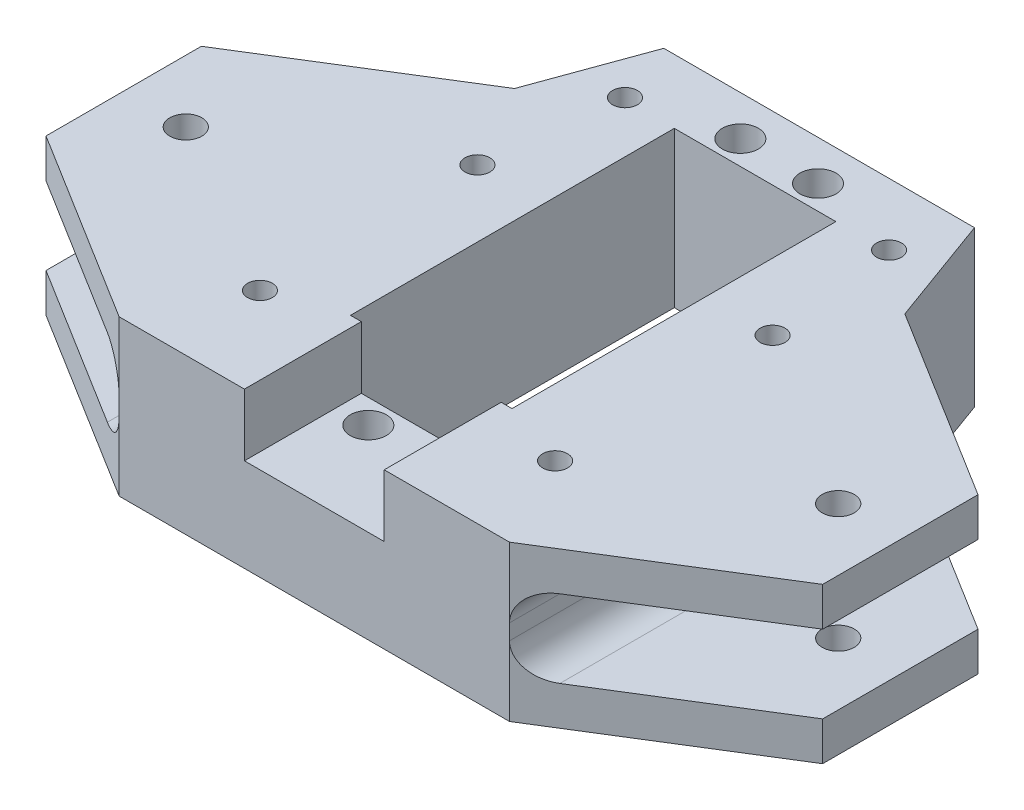
from build123d import *

# Parameters (mm, degrees)
MAIN_BODY_DEPTH           = 10
SKETCH2_R                 = 2.325
SKETCH2_R_2               = 2.0625
SKETCH2_W                 = 20.8
SKETCH2_H                 = 41.7
SERVO_ROTROD_CUTOUT_DEPTH = 30
SKETCH3_W                 = 18
SKETCH3_H                 = 8
SERVO_CABLE_CUTOUT_DEPTH  = 56.752305
CONTROL_ARM_CUTOUT_START  = -66
SKETCH4_W                 = 24.86969785
SKETCH4_H                 = 10
CONTROL_ARM_CUTOUT_DEPTH  = 67
FILLET1_R                 = 4
SKETCH6_R                 = 1.6
MOUNT_HOLES_CHASSIS_DEPTH = 21
SKETCH7_R                 = 3.25
BOLT_HEAD_HOLES_DEPTH     = 8


with BuildPart() as part:
    # Sketch1 → Main-Body (new body, symmetric)
    with BuildSketch(Plane(origin=(0, 0, 0), x_dir=(1, 0, 0), z_dir=(0, 1, 0))):
        Polygon((20, 39.547694656), (-20, 39.547694656), (-25.13030215, 25.452305344), (-50, 10), (-50, -10), (-25.13030215, -25.452305344), (25.13030215, -25.452305344), (50, -10), (50, 10), (25.13030215, 25.452305344), align=None)
    extrude(amount=MAIN_BODY_DEPTH, both=True)

    # Sketch2 → Servo&RotRod-Cutout (cut)
    with BuildSketch(Plane(origin=(0, 10, 0), x_dir=(1, 0, 0), z_dir=(0, 1, 0))):
        with Locations((-5, -13.5)):
            Circle(SKETCH2_R)
        with Locations((5, -13.5)):
            Circle(SKETCH2_R)
        with Locations((-5, 34.4)):
            Circle(SKETCH2_R)
        with Locations((5, 34.4)):
            Circle(SKETCH2_R)
        with Locations((-42, 0)):
            Circle(SKETCH2_R_2)
        with Locations((42, 0)):
            Circle(SKETCH2_R_2)
        with Locations((0, 10.45)):
            Rectangle(SKETCH2_W, SKETCH2_H)
    extrude(amount=-SERVO_ROTROD_CUTOUT_DEPTH, mode=Mode.SUBTRACT)

    # Sketch3 → Servo-Cable-Cutout (cut)
    with BuildSketch(Plane.XY.offset(25.452305344)):
        with Locations((0, 6)):
            Rectangle(SKETCH3_W, SKETCH3_H)
    extrude(amount=-SERVO_CABLE_CUTOUT_DEPTH, mode=Mode.SUBTRACT)

    # Sketch4 → Control-Arm-Cutout (cut)
    with BuildSketch(Plane.XY.offset(25.452305344).offset(CONTROL_ARM_CUTOUT_START)):
        with Locations((-37.565151075, 0)):
            Rectangle(SKETCH4_W, SKETCH4_H)
    control_arm_cutout = extrude(amount=CONTROL_ARM_CUTOUT_DEPTH, mode=Mode.SUBTRACT)

    # Mirror1: Control-Arm-Cutout across plane
    add(control_arm_cutout.mirror(Plane(origin=(0, 0, 0), x_dir=(0, 0, 1), z_dir=(1, 0, 0))), mode=Mode.SUBTRACT)

    # Fillet1
    fillet1_edges = [part.edges().sort_by_distance(p)[0] for p in [
        (-25.13030215, 5, 0),
        (-25.13030215, -5, 0),
        (25.13030215, -5, 0),
        (25.13030215, 5, 0),
    ]]
    fillet(fillet1_edges, radius=FILLET1_R)

    # Sketch6 → Mount-Holes-Chassis (cut, through all)
    with BuildSketch(Plane.XZ.offset(10)):
        with Locations((19, -14.547694656)):
            Circle(SKETCH6_R)
        with Locations((19, 13.452305344)):
            Circle(SKETCH6_R)
        with Locations((17, -31.547694656)):
            Circle(SKETCH6_R)
        with Locations((-17, -31.547694656)):
            Circle(SKETCH6_R)
        with Locations((-19, 13.452305344)):
            Circle(SKETCH6_R)
        with Locations((-19, -14.547694656)):
            Circle(SKETCH6_R)
    extrude(amount=-MOUNT_HOLES_CHASSIS_DEPTH, mode=Mode.SUBTRACT)

    # Sketch7 → Bolt-Head-Holes (cut)
    with BuildSketch(Plane.XZ.offset(10)):
        with Locations((17, -31.547694656)):
            Circle(SKETCH7_R)
        with Locations((19, -14.547694656)):
            Circle(SKETCH7_R)
        with Locations((19, 13.452305344)):
            Circle(SKETCH7_R)
        with Locations((-19, 13.452305344)):
            Circle(SKETCH7_R)
        with Locations((-19, -14.547694656)):
            Circle(SKETCH7_R)
        with Locations((-17, -31.547694656)):
            Circle(SKETCH7_R)
    extrude(amount=-BOLT_HEAD_HOLES_DEPTH, mode=Mode.SUBTRACT)


solid = part.part
